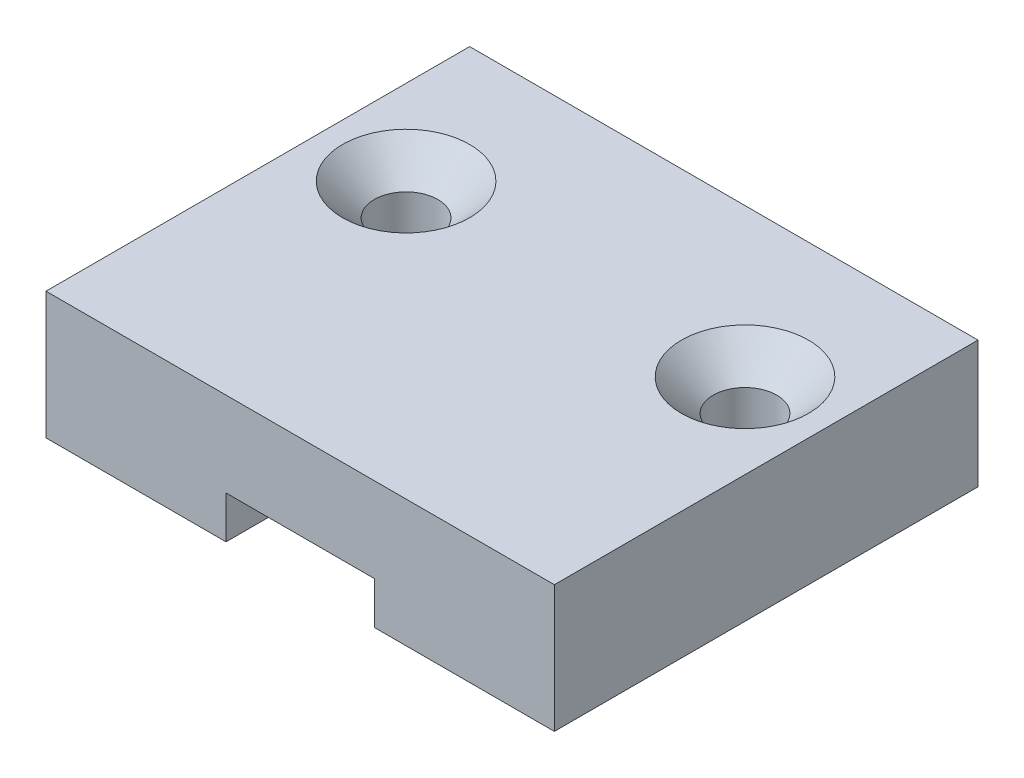
from build123d import *

# Parameters (mm, degrees)
ESQUISSE1_W             = 24
ESQUISSE1_H             = 20
ESQUISSE1_R             = 1.5
BOSS_EXTRU_1_DEPTH      = 6
ENL_V_MAT_EXTRU_1_DEPTH = 2
CHANFREIN1_SIZE         = 1.5


with BuildPart() as part:
    # Esquisse1 → Boss.-Extru.1 (new body)
    with BuildSketch(Plane(origin=(0, 0, 0), x_dir=(1, 0, 0), z_dir=(0, 1, 0))):
        with Locations((0, 10)):
            Rectangle(ESQUISSE1_W, ESQUISSE1_H)
        with Locations(Location((8, 13, 0), (0, 0, 270))):  # turned: the seam where the file's is
            Circle(ESQUISSE1_R, mode=Mode.SUBTRACT)
        with Locations(Location((-8, 13, 0), (0, 0, 90))):  # turned: the seam where the file's is
            Circle(ESQUISSE1_R, mode=Mode.SUBTRACT)
    extrude(amount=BOSS_EXTRU_1_DEPTH)

    # Esquisse2 → Enlèv. mat.-Extru.1 (cut)
    with BuildSketch(Plane.XZ):
        Polygon((3.5, 0), (3.5, -2), (7, -2), (7, -6), (6, -6), (6, -20), (-6, -20), (-6, -6), (-7, -6), (-7, -2), (-3.5, -2), (-3.5, 0), align=None)
    extrude(amount=-ENL_V_MAT_EXTRU_1_DEPTH, mode=Mode.SUBTRACT)

    # Chanfrein1
    chanfrein1_edges = [part.edges().sort_by_distance(p)[0] for p in [
        (8, 6, -14.5),
        (-8, 6, -11.5),
    ]]
    chamfer(chanfrein1_edges, length=CHANFREIN1_SIZE)


solid = part.part
